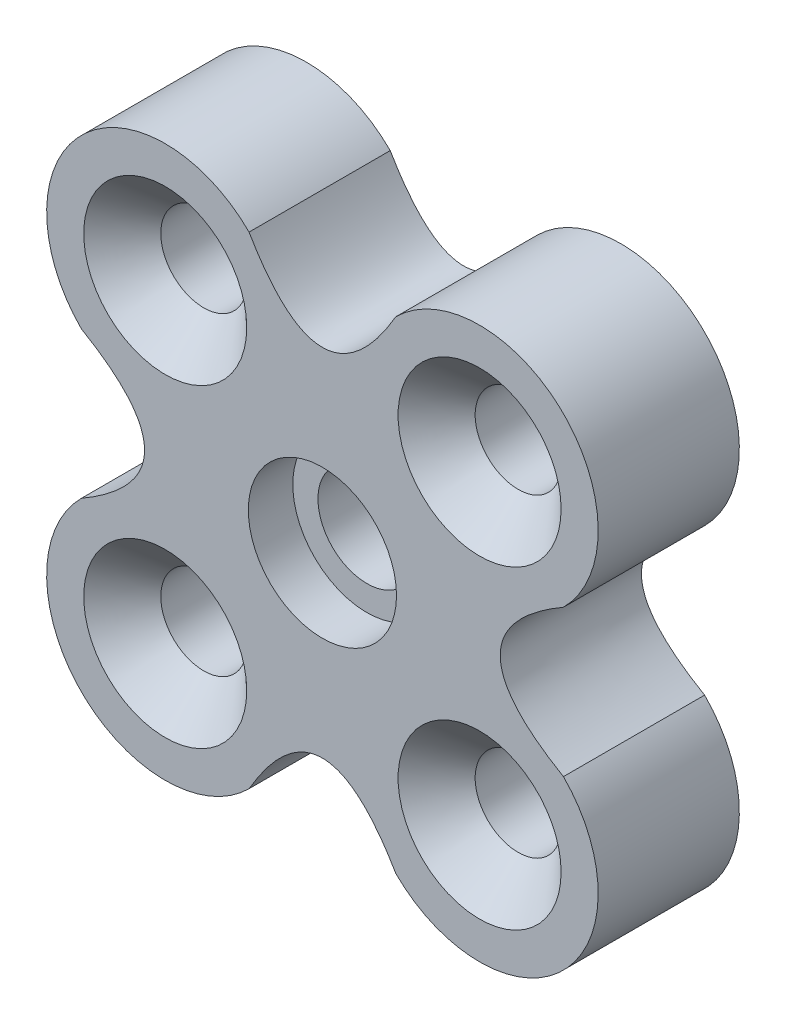
from build123d import *

# Parameters (mm, degrees)
BOSS_EXTRUDE1_DEPTH                               = 4.763
CSK_FOR_M2_5_FLAT_HEAD_MACHINE_SCREW1_D           = 2.9
CSK_FOR_M2_5_FLAT_HEAD_MACHINE_SCREW1_CSINK_D     = 5.5
CSK_FOR_M2_5_FLAT_HEAD_MACHINE_SCREW1_CSINK_ANGLE = 90
TAP_DRILL_FOR_M4X0_7_TAP1_D                       = 3.3
SKETCH8_R                                         = 2.5
CUT_EXTRUDE1_DEPTH                                = 1.5


with BuildPart() as part:
    # Sketch1 → Boss-Extrude1 (new body)
    with BuildSketch(Plane.XY):
        with BuildLine():
            ThreePointArc((-8.131727984, 2.474873734), (-8.131727984, 8.131727984), (-2.474873734, 8.131727984))
            add(Edge.make_bspline(
                [(-2.474873734, 8.131727984), (0, 3.868272016), (2.474873734, 8.131727984)],
                knots=[0, 0, 0, 1, 1, 1], degree=2))
            ThreePointArc((2.474873734, 8.131727984), (8.131727984, 8.131727984), (8.131727984, 2.474873734))
            add(Edge.make_bspline(
                [(8.131727984, 2.474873734), (3.868272016, 0), (8.131727984, -2.474873734)],
                knots=[0, 0, 0, 1, 1, 1], degree=2))
            ThreePointArc((8.131727984, -2.474873734), (8.131727984, -8.131727984), (2.474873734, -8.131727984))
            add(Edge.make_bspline(
                [(2.474873734, -8.131727984), (0, -3.868272016), (-2.474873734, -8.131727984)],
                knots=[0, 0, 0, 1, 1, 1], degree=2))
            ThreePointArc((-2.474873734, -8.131727984), (-8.131727984, -8.131727984), (-8.131727984, -2.474873734))
            add(Edge.make_bspline(
                [(-8.131727984, -2.474873734), (-3.868272016, 0), (-8.131727984, 2.474873734)],
                knots=[0, 0, 0, 1, 1, 1], degree=2))
        make_face()
    extrude(amount=BOSS_EXTRUDE1_DEPTH)

    # CSK for M2.5 Flat Head Machine Screw1 (through all)
    with Locations(Plane.XY.offset(4.763)):
        with Locations((-5.303300859, 5.303300859), (5.303300859, 5.303300859), (5.303300859, -5.303300859), (-5.303300859, -5.303300859)):
            CounterSinkHole(CSK_FOR_M2_5_FLAT_HEAD_MACHINE_SCREW1_D / 2, CSK_FOR_M2_5_FLAT_HEAD_MACHINE_SCREW1_CSINK_D / 2, counter_sink_angle=CSK_FOR_M2_5_FLAT_HEAD_MACHINE_SCREW1_CSINK_ANGLE)

    # Tap Drill for M4x0.7 Tap1 (through all)
    with Locations(Plane.XY.offset(4.763)):
        with Locations((0, 0)):
            Hole(TAP_DRILL_FOR_M4X0_7_TAP1_D / 2)

    # Sketch8 → Cut-Extrude1 (cut)
    with BuildSketch(Plane.XY.offset(4.763)):
        Circle(SKETCH8_R)
    extrude(amount=-CUT_EXTRUDE1_DEPTH, mode=Mode.SUBTRACT)


solid = part.part
